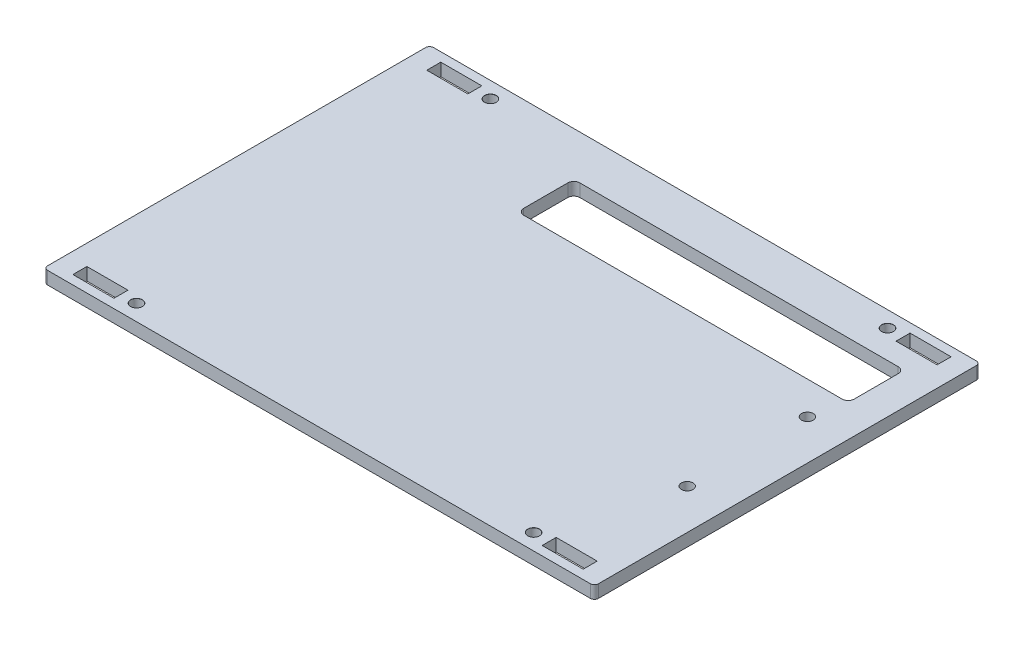
from build123d import *

# Parameters (mm, degrees)
SKETCH1_W                                      = 137.49
SKETCH1_H                                      = 96.345
BOSS_EXTRUDE1_DEPTH                            = 3.175
SKETCH1_3_W                                    = 10.25
SKETCH1_3_H                                    = 3.4925
CUT_EXTRUDE1_DEPTH                             = 85.003246403
M2_5_CLEARANCE_HOLE1_D                         = 2.9
M2_5_CLEARANCE_HOLE1_CSINK_D                   = 2.95
M2_5_CLEARANCE_HOLE1_CSINK_ANGLE               = 100
MIRROR1_AT_THE_SECOND_PLANE_COPY_1_SKETC_W     = 10.25
MIRROR1_AT_THE_SECOND_PLANE_COPY_1_SKETC_H     = 3.4925
MIRROR1_AT_THE_SECOND_PLANE_COPY_1_DEPTH       = 85.003246403
MIRROR1_AT_THE_SECOND_PLANE_COPY_2_D           = 2.9
MIRROR1_AT_THE_SECOND_PLANE_COPY_2_CSINK_D     = 2.95
MIRROR1_AT_THE_SECOND_PLANE_COPY_2_CSINK_ANGLE = 100
CUT_EXTRUDE2_DEPTH                             = 85.003246403
CUT_EXTRUDE2_DEPTH_BACK                        = 85.003246403
SKETCH4_W                                      = 82.49
SKETCH4_H                                      = 14
FILLET1_R                                      = 1.5
FILLET2_R                                      = 1
M2_5_CLEARANCE_HOLE2_D                         = 2.9


with BuildPart() as part:
    # Sketch1 → Boss-Extrude1 (new body)
    with BuildSketch(Plane(origin=(0, 0, 0), x_dir=(1, 0, 0), z_dir=(0, 1, 0))):
        Rectangle(SKETCH1_W, SKETCH1_H)
    extrude(amount=BOSS_EXTRUDE1_DEPTH)

    # Sketch1_3 → Cut-Extrude1 (cut, symmetric)
    with BuildSketch(Plane(origin=(0, 0, 0), x_dir=(1, 0, 0), z_dir=(0, 1, 0))):
        with Locations((-58.57, 44.1725)):
            Rectangle(SKETCH1_3_W, SKETCH1_3_H)
    cut_extrude1 = extrude(amount=CUT_EXTRUDE1_DEPTH, both=True, mode=Mode.SUBTRACT)

    # M2.5 Clearance Hole1 (through all)
    with Locations(Plane(origin=(0, 3.175, 0), x_dir=(1, 0, 0), z_dir=(0, 1, 0))):
        with Locations((-49.57, 44.1725)):
            m2_5_clearance_hole1 = CounterSinkHole(M2_5_CLEARANCE_HOLE1_D / 2, M2_5_CLEARANCE_HOLE1_CSINK_D / 2, counter_sink_angle=M2_5_CLEARANCE_HOLE1_CSINK_ANGLE)

    # Mirror1: Cut-Extrude1, M2.5 Clearance Hole1 across plane
    add(cut_extrude1.mirror(Plane(origin=(0, 0, 0), x_dir=(0, 0, 1), z_dir=(1, 0, 0))), mode=Mode.SUBTRACT)
    add(m2_5_clearance_hole1.mirror(Plane(origin=(0, 0, 0), x_dir=(0, 0, 1), z_dir=(1, 0, 0))), mode=Mode.SUBTRACT)

    # Mirror1 at the second plane: Cut-Extrude1, M2.5 Clearance Hole1 across plane
    add(cut_extrude1.mirror(Plane.XY), mode=Mode.SUBTRACT)
    add(m2_5_clearance_hole1.mirror(Plane.XY), mode=Mode.SUBTRACT)

    # Mirror1 at the second plane copy 1 sketc → Mirror1 at the second plane copy 1 (cut, symmetric)
    with BuildSketch(Plane(origin=(0, 0, 0), x_dir=(-1, 0, 0), z_dir=(0, 1, 0))):
        with Locations((-58.57, 44.1725)):
            Rectangle(MIRROR1_AT_THE_SECOND_PLANE_COPY_1_SKETC_W, MIRROR1_AT_THE_SECOND_PLANE_COPY_1_SKETC_H)
    extrude(amount=MIRROR1_AT_THE_SECOND_PLANE_COPY_1_DEPTH, both=True, mode=Mode.SUBTRACT)

    # Mirror1 at the second plane copy 2 (through all)
    with Locations(Plane(origin=(0, 3.175, 0), x_dir=(-1, 0, 0), z_dir=(0, 1, 0))):
        with Locations((-49.57, 44.1725)):
            CounterSinkHole(MIRROR1_AT_THE_SECOND_PLANE_COPY_2_D / 2, MIRROR1_AT_THE_SECOND_PLANE_COPY_2_CSINK_D / 2, counter_sink_angle=MIRROR1_AT_THE_SECOND_PLANE_COPY_2_CSINK_ANGLE)

    # Sketch4 → Cut-Extrude2 (cut, two sides: drawn at the far end of the back side and taken through both)
    with BuildSketch(Plane(origin=(0, 3.175, 0), x_dir=(1, 0, 0), z_dir=(0, 1, 0)).offset(-CUT_EXTRUDE2_DEPTH_BACK)):
        with Locations((19.5, 30.1725)):
            Rectangle(SKETCH4_W, SKETCH4_H)
    extrude(amount=CUT_EXTRUDE2_DEPTH + CUT_EXTRUDE2_DEPTH_BACK, mode=Mode.SUBTRACT)

    # Fillet1
    fillet1_edges = [part.edges().sort_by_distance(p)[0] for p in [
        (-21.745, 1.5875, -23.1725),
        (60.745, 1.5875, -23.1725),
        (60.745, 1.5875, -37.1725),
        (-21.745, 1.5875, -37.1725),
    ]]
    fillet(fillet1_edges, radius=FILLET1_R)

    # Fillet2
    fillet2_edges = [part.edges().sort_by_distance(p)[0] for p in [
        (68.745, 1.5875, 48.1725),
        (-68.745, 1.5875, 48.1725),
        (-68.745, 1.5875, -48.1725),
        (68.745, 1.5875, -48.1725),
    ]]
    fillet(fillet2_edges, radius=FILLET2_R)

    # M2.5 Clearance Hole2 (through all)
    with Locations(Plane(origin=(0, 3.175, 0), x_dir=(1, 0, 0), z_dir=(0, 1, 0))):
        with Locations((58.745, 15), (58.745, -15)):
            Hole(M2_5_CLEARANCE_HOLE2_D / 2)


solid = part.part
